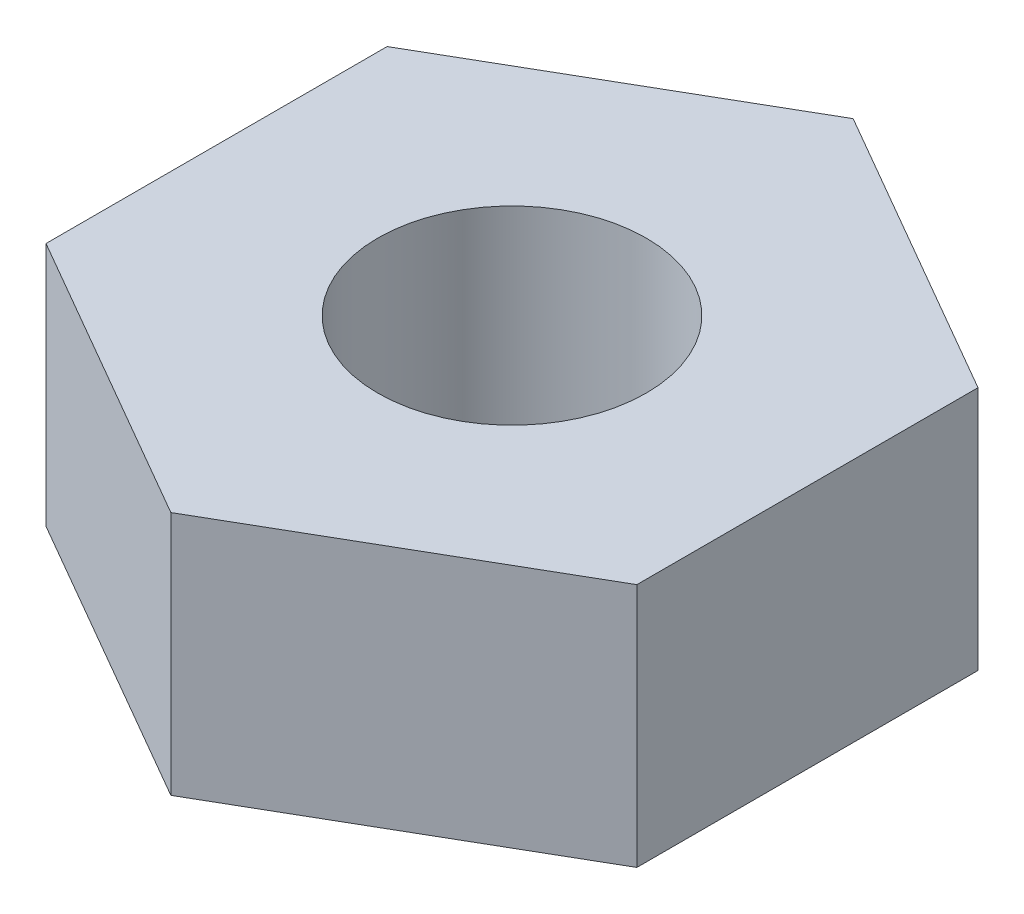
from build123d import *

# Parameters (mm, degrees)
SKETCH1_R           = 1.25
BOSS_EXTRUDE1_DEPTH = 2.28


with BuildPart() as part:
    # Sketch1 → Boss-Extrude1 (new body)
    with BuildSketch(Plane(origin=(0, 0, 0), x_dir=(1, 0, 0), z_dir=(0, 1, 0))):
        Polygon((0, -3.175426481), (2.75, -1.58771324), (2.75, 1.58771324), (0, 3.175426481), (-2.75, 1.58771324), (-2.75, -1.58771324), align=None)
        Circle(SKETCH1_R, mode=Mode.SUBTRACT)
    extrude(amount=BOSS_EXTRUDE1_DEPTH)


solid = part.part
